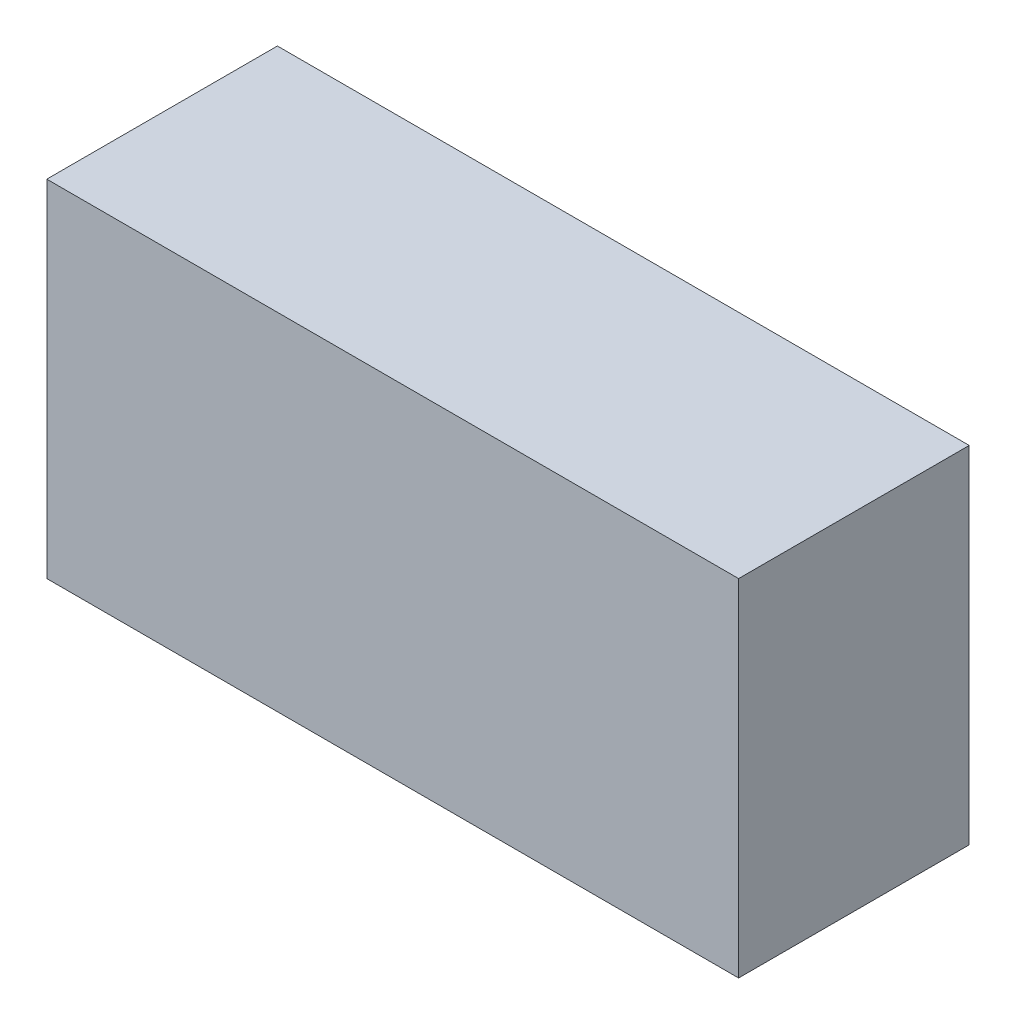
from build123d import *

# Parameters (mm, degrees)
SZKIC2_W                    = 60
SZKIC2_H                    = 30
DODANIE_WYCI_GNI_CIE1_DEPTH = 20


with BuildPart() as part:
    # Szkic2 → Dodanie-wyciągnięcie1 (new body)
    with BuildSketch(Plane.XY):
        with Locations((2.23880597, 49.253731343)):
            Rectangle(SZKIC2_W, SZKIC2_H)
    extrude(amount=DODANIE_WYCI_GNI_CIE1_DEPTH)


solid = part.part
